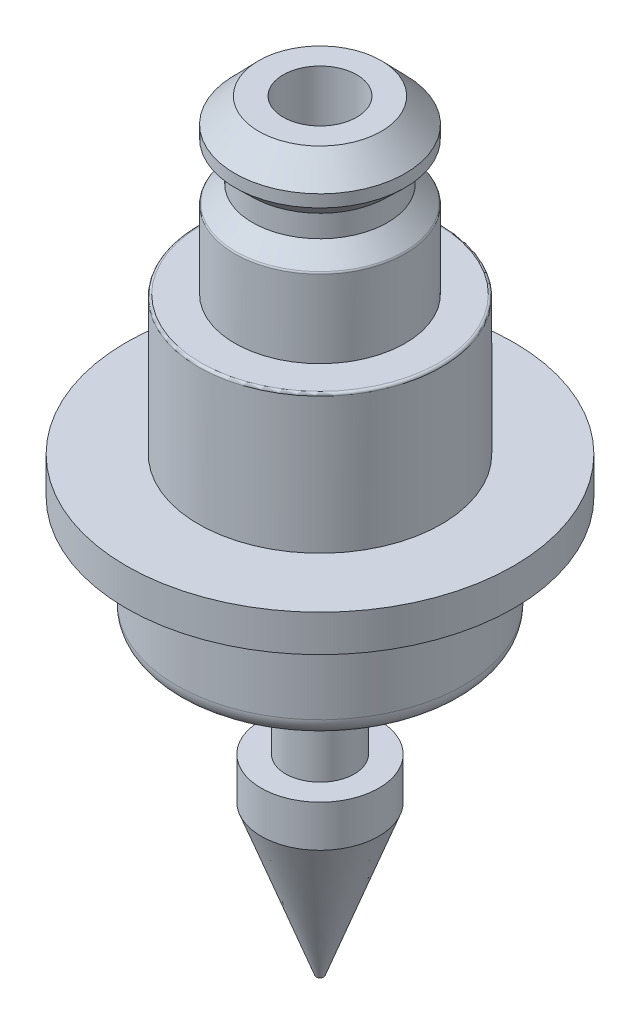
from build123d import *

# Parameters (mm, degrees)
FILLET1_R = 0.75
FILLET2_R = 0.1


with BuildPart() as part:
    # Sketch1 → Revolve1 (revolve)
    with BuildSketch(Plane.XY):
        Polygon((1.5, 14.15), (2.5, 14.15), (3.475, 13.15), (3.475, 12.65), (2.75, 11.95), (2.75, 11.05), (3.475, 10.35), (3.475, 7.15), (4.955, 7.15), (4.955, 1.5), (7.9, 1.5), (7.9, 0), (5.85, 0), (5.85, -4.5), (1.4, -4.5), (1.4, -9.1), (2.4, -9.1), (2.4, -10.8), (0.15, -16.9), (0.15, 0), (1.5, 0), align=None)
    revolve(axis=Axis((0, 0, 0), (0, 1, 0)))

    # Fillet1
    fillet1_edges = [part.edges().sort_by_distance(p)[0] for p in [
        (-5.85, -4.5, 0),
    ]]
    fillet(fillet1_edges, radius=FILLET1_R)

    # Fillet2
    fillet2_edges = [part.edges().sort_by_distance(p)[0] for p in [
        (-4.955, 7.15, 0),
        (-3.475, 10.35, 0),
    ]]
    fillet(fillet2_edges, radius=FILLET2_R)


solid = part.part
